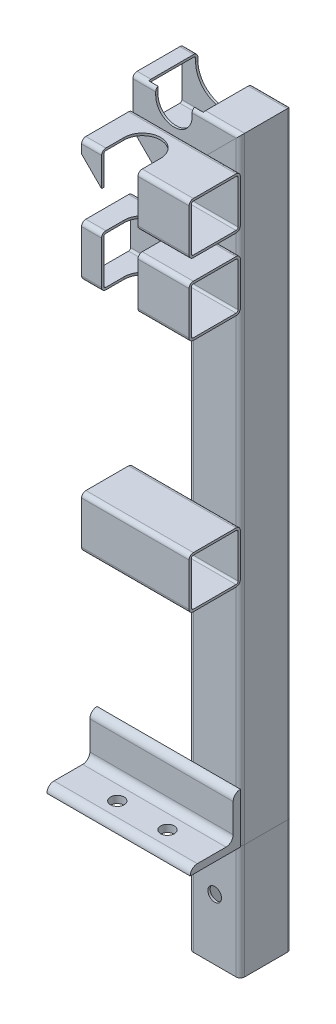
from build123d import *

# Parameters (mm, degrees)
STRUCTURAL_MEMBER1_DEPTH      = 1
STRUCTURAL_MEMBER1_DEPTH_BACK = 80
STRUCTURAL_MEMBER1_2_DEPTH    = 439.314422766
STRUCTURAL_MEMBER1_3_DEPTH    = 83.414422766
CUT_EXTRUDE1_DEPTH            = 477.333226324
CUT_EXTRUDE1_DEPTH_BACK       = 477.333226324
STRUCTURAL_MEMBER2_DEPTH      = 100
SKETCH15_R                    = 4.7625
CUT_EXTRUDE2_DEPTH            = 479.927283103
CUT_EXTRUDE3_START            = -17.9
CUT_EXTRUDE3_DEPTH            = 34.2
STRUCTURAL_MEMBER3_DEPTH      = 75
STRUCTURAL_MEMBER3_2_DEPTH    = 75
STRUCTURAL_MEMBER3_3_DEPTH    = 75
CUT_EXTRUDE4_DEPTH            = 300
CUT_EXTRUDE5_DEPTH            = 480.016307134
SKETCH22_R                    = 4.7625
CUT_EXTRUDE6_DEPTH            = 478.34114897


with BuildPart() as part:
    # Sketch11 → Structural Member1 (new, two sides)
    with BuildSketch(Plane(origin=(186.45, 0, 0), x_dir=(-1, 0, 0), z_dir=(0, 1, 0))) as structural_member1_sk:
        with BuildLine():
            Line((-14.9, 17.9), (14.9, 17.9))
            ThreePointArc((14.9, 17.9), (17.021320344, 17.021320344), (17.9, 14.9))
            Line((17.9, 14.9), (17.9, -14.9))
            ThreePointArc((17.9, -14.9), (17.021320344, -17.021320344), (14.9, -17.9))
            Line((14.9, -17.9), (-14.9, -17.9))
            ThreePointArc((-14.9, -17.9), (-17.021320344, -17.021320344), (-17.9, -14.9))
            Line((-17.9, -14.9), (-17.9, 14.9))
            ThreePointArc((-17.9, 14.9), (-17.021320344, 17.021320344), (-14.9, 17.9))
        make_face()
        with BuildLine():
            Line((-14.9, 16.3), (14.9, 16.3))
            ThreePointArc((14.9, 16.3), (15.889949494, 15.889949494), (16.3, 14.9))
            Line((16.3, 14.9), (16.3, -14.9))
            ThreePointArc((16.3, -14.9), (15.889949494, -15.889949494), (14.9, -16.3))
            Line((14.9, -16.3), (-14.9, -16.3))
            ThreePointArc((-14.9, -16.3), (-15.889949494, -15.889949494), (-16.3, -14.9))
            Line((-16.3, -14.9), (-16.3, 14.9))
            ThreePointArc((-16.3, 14.9), (-15.889949494, 15.889949494), (-14.9, 16.3))
        make_face(mode=Mode.SUBTRACT)
    extrude(amount=STRUCTURAL_MEMBER1_DEPTH)
    extrude(structural_member1_sk.sketch, amount=-STRUCTURAL_MEMBER1_DEPTH_BACK)

    # Structural Member1 mitre 1
    split(bisect_by=Plane(origin=(186.45, 0, 0), x_dir=(1, 0, 0), z_dir=(0, -1, 0)), keep=Keep.TOP)

    # Sketch22 → Cut-Extrude6 (cut, through all)
    with BuildSketch(Plane.XY.offset(17.9)):
        with Locations((186.45, -37.5)):
            Circle(SKETCH22_R)
    extrude(amount=-CUT_EXTRUDE6_DEPTH, mode=Mode.SUBTRACT)


with BuildPart() as body_2:
    # Sketch11 on segment 2 (carried to segment 2) → Structural Member1 2 (new body)
    with BuildSketch(Plane(origin=(186.45, -1, 0), x_dir=(-1, 0, 0), z_dir=(0, 1, 0))):
        with BuildLine():
            Line((-14.9, 17.9), (14.9, 17.9))
            ThreePointArc((14.9, 17.9), (17.021320344, 17.021320344), (17.9, 14.9))
            Line((17.9, 14.9), (17.9, -14.9))
            ThreePointArc((17.9, -14.9), (17.021320344, -17.021320344), (14.9, -17.9))
            Line((14.9, -17.9), (-14.9, -17.9))
            ThreePointArc((-14.9, -17.9), (-17.021320344, -17.021320344), (-17.9, -14.9))
            Line((-17.9, -14.9), (-17.9, 14.9))
            ThreePointArc((-17.9, 14.9), (-17.021320344, 17.021320344), (-14.9, 17.9))
        make_face()
        with BuildLine():
            Line((-14.9, 16.3), (14.9, 16.3))
            ThreePointArc((14.9, 16.3), (15.889949494, 15.889949494), (16.3, 14.9))
            Line((16.3, 14.9), (16.3, -14.9))
            ThreePointArc((16.3, -14.9), (15.889949494, -15.889949494), (14.9, -16.3))
            Line((14.9, -16.3), (-14.9, -16.3))
            ThreePointArc((-14.9, -16.3), (-15.889949494, -15.889949494), (-16.3, -14.9))
            Line((-16.3, -14.9), (-16.3, 14.9))
            ThreePointArc((-16.3, 14.9), (-15.889949494, 15.889949494), (-14.9, 16.3))
        make_face(mode=Mode.SUBTRACT)
    extrude(amount=STRUCTURAL_MEMBER1_2_DEPTH)

    # Structural Member1 2 mitre 1
    split(bisect_by=Plane(origin=(186.45, 0, 0), x_dir=(-1, 0, 0), z_dir=(0, 1, 0)), keep=Keep.TOP)

    # Structural Member1 2 mitre 2
    split(bisect_by=Plane(origin=(186.45, 412, 0), x_dir=(0.707106781, 0.707106781, 0), z_dir=(0.707106781, -0.707106781, 0)), keep=Keep.TOP)


with BuildPart() as body_3:
    # Sketch11 on segment 3 (carried to segment 3) → Structural Member1 3 (new body)
    with BuildSketch(Plane(origin=(212.764422766, 412, 0), x_dir=(0, -1, 0), z_dir=(-1, 0, 0))):
        with BuildLine():
            Line((-14.9, 17.9), (14.9, 17.9))
            ThreePointArc((14.9, 17.9), (17.021320344, 17.021320344), (17.9, 14.9))
            Line((17.9, 14.9), (17.9, -14.9))
            ThreePointArc((17.9, -14.9), (17.021320344, -17.021320344), (14.9, -17.9))
            Line((14.9, -17.9), (-14.9, -17.9))
            ThreePointArc((-14.9, -17.9), (-17.021320344, -17.021320344), (-17.9, -14.9))
            Line((-17.9, -14.9), (-17.9, 14.9))
            ThreePointArc((-17.9, 14.9), (-17.021320344, 17.021320344), (-14.9, 17.9))
        make_face()
        with BuildLine():
            Line((-14.9, 16.3), (14.9, 16.3))
            ThreePointArc((14.9, 16.3), (15.889949494, 15.889949494), (16.3, 14.9))
            Line((16.3, 14.9), (16.3, -14.9))
            ThreePointArc((16.3, -14.9), (15.889949494, -15.889949494), (14.9, -16.3))
            Line((14.9, -16.3), (-14.9, -16.3))
            ThreePointArc((-14.9, -16.3), (-15.889949494, -15.889949494), (-16.3, -14.9))
            Line((-16.3, -14.9), (-16.3, 14.9))
            ThreePointArc((-16.3, 14.9), (-15.889949494, 15.889949494), (-14.9, 16.3))
        make_face(mode=Mode.SUBTRACT)
    extrude(amount=STRUCTURAL_MEMBER1_3_DEPTH)

    # Structural Member1 3 mitre 1
    split(bisect_by=Plane(origin=(186.45, 412, 0), x_dir=(-0.707106781, -0.707106781, 0), z_dir=(-0.707106781, 0.707106781, 0)), keep=Keep.TOP)

    # Sketch12 → Cut-Extrude1 (cut, two sides)
    with BuildSketch(Plane.XY) as cut_extrude1_sk:
        with BuildLine():
            Line((145.3, 424.7), (145.3, 435.1))
            ThreePointArc((145.3, 435.1), (158, 447.8), (170.7, 435.1))
            Line((170.7, 435.1), (170.7, 424.7))
            ThreePointArc((170.7, 424.7), (158, 412), (145.3, 424.7))
        make_face()
    extrude(amount=CUT_EXTRUDE1_DEPTH, mode=Mode.SUBTRACT)
    extrude(cut_extrude1_sk.sketch, amount=-CUT_EXTRUDE1_DEPTH_BACK, mode=Mode.SUBTRACT)

    # Sketch16 → Cut-Extrude3 (cut)
    with BuildSketch(Plane.XY.offset(CUT_EXTRUDE3_START)):
        with BuildLine():
            Line((177.05, 424.7), (177.05, 435.1))
            ThreePointArc((177.05, 435.1), (158, 454.15), (138.95, 435.1))
            Line((138.95, 435.1), (138.95, 424.7))
            ThreePointArc((138.95, 424.7), (158, 405.65), (177.05, 424.7))
        make_face()
    extrude(amount=CUT_EXTRUDE3_DEPTH, mode=Mode.SUBTRACT)


with BuildPart() as body_4:
    # Sketch14 → Structural Member2 (new body)
    with BuildSketch(Plane(origin=(104.35, 0, 17.9), x_dir=(0, 1, 0), z_dir=(1, 0, 0))):
        with BuildLine():
            Line((0, 0), (0, 35))
            ThreePointArc((0, 35), (3.535533906, 33.535533906), (5, 30))
            Line((5, 30), (5, 10))
            ThreePointArc((5, 10), (6.464466094, 6.464466094), (10, 5))
            Line((10, 5), (30, 5))
            ThreePointArc((30, 5), (33.535533906, 3.535533906), (35, 0))
            Line((35, 0), (0, 0))
        make_face()
    extrude(amount=STRUCTURAL_MEMBER2_DEPTH)

    # Sketch15 → Cut-Extrude2 (cut, through all)
    with BuildSketch(Plane(origin=(0, 0, 0), x_dir=(1, 0, 0), z_dir=(0, 1, 0))):
        with Locations(Location((138.5, -37.9, 0), (0, 0, 90))):
            Circle(SKETCH15_R)
        with Locations(Location((173.5, -37.9, 0), (0, 0, 90))):
            Circle(SKETCH15_R)
    extrude(amount=CUT_EXTRUDE2_DEPTH, mode=Mode.SUBTRACT)


with BuildPart() as body_5:
    # Sketch19 → Structural Member3 (new body)
    with BuildSketch(Plane(origin=(204.35, 390.5, 35.8), x_dir=(0, -1, 0), z_dir=(-1, 0, 0))):
        with BuildLine():
            Line((-14.9, 17.9), (14.9, 17.9))
            ThreePointArc((14.9, 17.9), (17.021320344, 17.021320344), (17.9, 14.9))
            Line((17.9, 14.9), (17.9, -14.9))
            ThreePointArc((17.9, -14.9), (17.021320344, -17.021320344), (14.9, -17.9))
            Line((14.9, -17.9), (-14.9, -17.9))
            ThreePointArc((-14.9, -17.9), (-17.021320344, -17.021320344), (-17.9, -14.9))
            Line((-17.9, -14.9), (-17.9, 14.9))
            ThreePointArc((-17.9, 14.9), (-17.021320344, 17.021320344), (-14.9, 17.9))
        make_face()
        with BuildLine():
            Line((-14.9, 16.3), (14.9, 16.3))
            ThreePointArc((14.9, 16.3), (15.889949494, 15.889949494), (16.3, 14.9))
            Line((16.3, 14.9), (16.3, -14.9))
            ThreePointArc((16.3, -14.9), (15.889949494, -15.889949494), (14.9, -16.3))
            Line((14.9, -16.3), (-14.9, -16.3))
            ThreePointArc((-14.9, -16.3), (-15.889949494, -15.889949494), (-16.3, -14.9))
            Line((-16.3, -14.9), (-16.3, 14.9))
            ThreePointArc((-16.3, 14.9), (-15.889949494, 15.889949494), (-14.9, 16.3))
        make_face(mode=Mode.SUBTRACT)
    extrude(amount=STRUCTURAL_MEMBER3_DEPTH)


with BuildPart() as body_6:
    # Sketch19 on segment 2 (carried to segment 2) → Structural Member3 2 (new body)
    with BuildSketch(Plane(origin=(204.35, 340.5, 35.8), x_dir=(0, -1, 0), z_dir=(-1, 0, 0))):
        with BuildLine():
            Line((-14.9, 17.9), (14.9, 17.9))
            ThreePointArc((14.9, 17.9), (17.021320344, 17.021320344), (17.9, 14.9))
            Line((17.9, 14.9), (17.9, -14.9))
            ThreePointArc((17.9, -14.9), (17.021320344, -17.021320344), (14.9, -17.9))
            Line((14.9, -17.9), (-14.9, -17.9))
            ThreePointArc((-14.9, -17.9), (-17.021320344, -17.021320344), (-17.9, -14.9))
            Line((-17.9, -14.9), (-17.9, 14.9))
            ThreePointArc((-17.9, 14.9), (-17.021320344, 17.021320344), (-14.9, 17.9))
        make_face()
        with BuildLine():
            Line((-14.9, 16.3), (14.9, 16.3))
            ThreePointArc((14.9, 16.3), (15.889949494, 15.889949494), (16.3, 14.9))
            Line((16.3, 14.9), (16.3, -14.9))
            ThreePointArc((16.3, -14.9), (15.889949494, -15.889949494), (14.9, -16.3))
            Line((14.9, -16.3), (-14.9, -16.3))
            ThreePointArc((-14.9, -16.3), (-15.889949494, -15.889949494), (-16.3, -14.9))
            Line((-16.3, -14.9), (-16.3, 14.9))
            ThreePointArc((-16.3, 14.9), (-15.889949494, 15.889949494), (-14.9, 16.3))
        make_face(mode=Mode.SUBTRACT)
    extrude(amount=STRUCTURAL_MEMBER3_2_DEPTH)


with BuildPart() as body_7:
    # Sketch19 on segment 3 (carried to segment 3) → Structural Member3 3 (new body)
    with BuildSketch(Plane(origin=(204.35, 176.5, 35.8), x_dir=(0, -1, 0), z_dir=(-1, 0, 0))):
        with BuildLine():
            Line((-14.9, 17.9), (14.9, 17.9))
            ThreePointArc((14.9, 17.9), (17.021320344, 17.021320344), (17.9, 14.9))
            Line((17.9, 14.9), (17.9, -14.9))
            ThreePointArc((17.9, -14.9), (17.021320344, -17.021320344), (14.9, -17.9))
            Line((14.9, -17.9), (-14.9, -17.9))
            ThreePointArc((-14.9, -17.9), (-17.021320344, -17.021320344), (-17.9, -14.9))
            Line((-17.9, -14.9), (-17.9, 14.9))
            ThreePointArc((-17.9, 14.9), (-17.021320344, 17.021320344), (-14.9, 17.9))
        make_face()
        with BuildLine():
            Line((-14.9, 16.3), (14.9, 16.3))
            ThreePointArc((14.9, 16.3), (15.889949494, 15.889949494), (16.3, 14.9))
            Line((16.3, 14.9), (16.3, -14.9))
            ThreePointArc((16.3, -14.9), (15.889949494, -15.889949494), (14.9, -16.3))
            Line((14.9, -16.3), (-14.9, -16.3))
            ThreePointArc((-14.9, -16.3), (-15.889949494, -15.889949494), (-16.3, -14.9))
            Line((-16.3, -14.9), (-16.3, 14.9))
            ThreePointArc((-16.3, 14.9), (-15.889949494, 15.889949494), (-14.9, 16.3))
        make_face(mode=Mode.SUBTRACT)
    extrude(amount=STRUCTURAL_MEMBER3_3_DEPTH)


with BuildPart() as cut_extrude4_tool:
    # Sketch20 → Cut-Extrude4 (new body)
    with BuildSketch(Plane(origin=(0, 408.4, 0), x_dir=(1, 0, 0), z_dir=(0, 1, 0))):
        with BuildLine():
            Line((168.7, -37.9), (168.7, -69.5))
            ThreePointArc((168.7, -69.5), (156, -82.2), (143.3, -69.5))
            Line((143.3, -69.5), (143.3, -37.9))
            ThreePointArc((143.3, -37.9), (156, -25.2), (168.7, -37.9))
        make_face()
    extrude(amount=-CUT_EXTRUDE4_DEPTH)


with BuildPart() as body_5_1:
    add(body_5.part)

    # Cut-Extrude4: cut by cut_extrude4_tool
    add(cut_extrude4_tool.part, mode=Mode.SUBTRACT)

    # Sketch21 → Cut-Extrude5 (cut, through all)
    with BuildSketch(Plane.XY):
        Polygon((129.35, 399.25), (156, 372.6), (156, 362.976287092), (122.496876684, 362.976287092), (122.496876684, 399.25), align=None)
    extrude(amount=CUT_EXTRUDE5_DEPTH, mode=Mode.SUBTRACT)


with BuildPart() as body_6_1:
    add(body_6.part)

    # Cut-Extrude4: cut by cut_extrude4_tool
    add(cut_extrude4_tool.part, mode=Mode.SUBTRACT)


solid = Compound([part.part, body_2.part, body_3.part, body_4.part, body_7.part, body_5_1.part, body_6_1.part])
